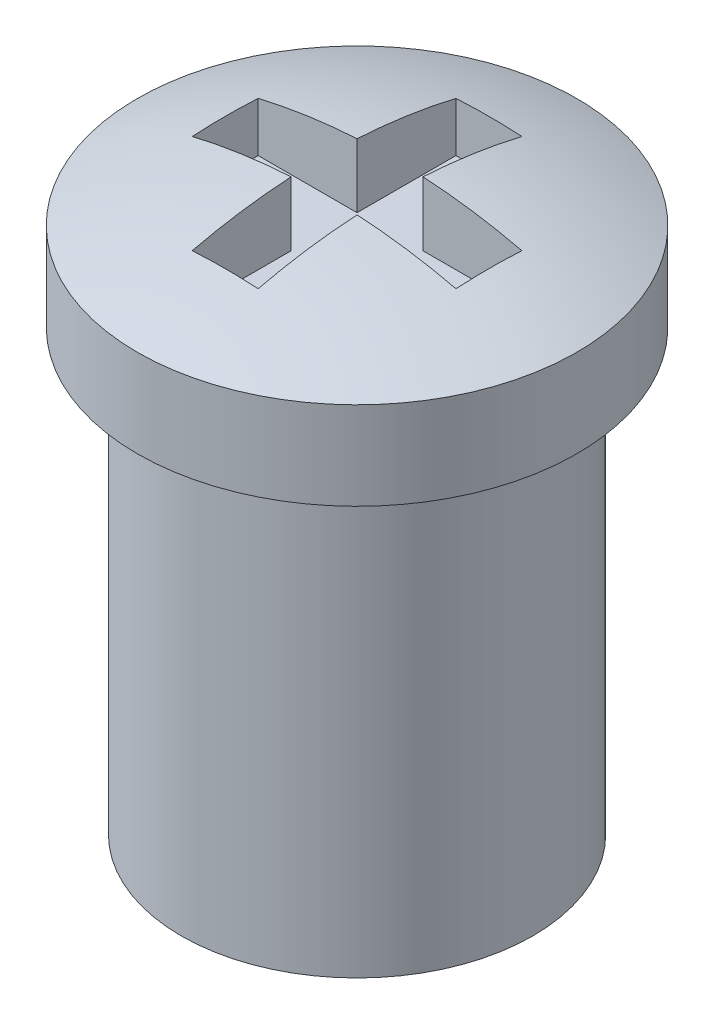
from build123d import *

# Parameters (mm, degrees)
SKETCH1_R           = 2
BOSS_EXTRUDE1_DEPTH = 5
SKETCH2_R           = 2.5
BOSS_EXTRUDE2_DEPTH = 1
DOME1_FACE_RADIUS   = 2.5
DOME1_HEIGHT        = 0.5
SKETCH3_W           = 1.125
SKETCH3_H           = 0.75
SKETCH3_W_2         = 0.75
SKETCH3_H_2         = 1.125
CUT_EXTRUDE1_DEPTH  = 0.75


with BuildPart() as part:
    # Sketch1 → Boss-Extrude1 (new body)
    with BuildSketch(Plane(origin=(0, 0, 0), x_dir=(1, 0, 0), z_dir=(0, 1, 0))):
        Circle(SKETCH1_R)
    extrude(amount=BOSS_EXTRUDE1_DEPTH)

    # Sketch2 → Boss-Extrude2 (add)
    with BuildSketch(Plane(origin=(0, 5, 0), x_dir=(1, 0, 0), z_dir=(0, 1, 0))):
        Circle(SKETCH2_R)
    extrude(amount=BOSS_EXTRUDE2_DEPTH)

    # Dome1: a dome of height H over a round flat face of radius A is a cap of a sphere of radius (A * A + H * H) / (2 * H)
    dome1_r = (DOME1_FACE_RADIUS * DOME1_FACE_RADIUS + DOME1_HEIGHT * DOME1_HEIGHT) / (2 * DOME1_HEIGHT)
    dome1_base = Plane((0, 6, 0), z_dir=(0, 1, 0))
    with Locations(dome1_base.offset(DOME1_HEIGHT - dome1_r)):
        dome1_ball = Sphere(dome1_r, mode=Mode.PRIVATE)
    add(split(dome1_ball, bisect_by=dome1_base, keep=Keep.TOP, mode=Mode.PRIVATE))

    # Sketch3 → Cut-Extrude1 (cut)
    with BuildSketch(Plane(origin=(0, 6.5, 0), x_dir=(1, 0, 0), z_dir=(0, 1, 0))):
        with Locations((-0.9375, 0)):
            Rectangle(SKETCH3_W, SKETCH3_H)
        Rectangle(SKETCH3_W_2, SKETCH3_H)
        with Locations((0, 0.9375)):
            Rectangle(SKETCH3_W_2, SKETCH3_H_2)
        with Locations((0.9375, 0)):
            Rectangle(SKETCH3_W, SKETCH3_H)
        with Locations((0, -0.9375)):
            Rectangle(SKETCH3_W_2, SKETCH3_H_2)
    extrude(amount=-CUT_EXTRUDE1_DEPTH, mode=Mode.SUBTRACT)


solid = part.part
